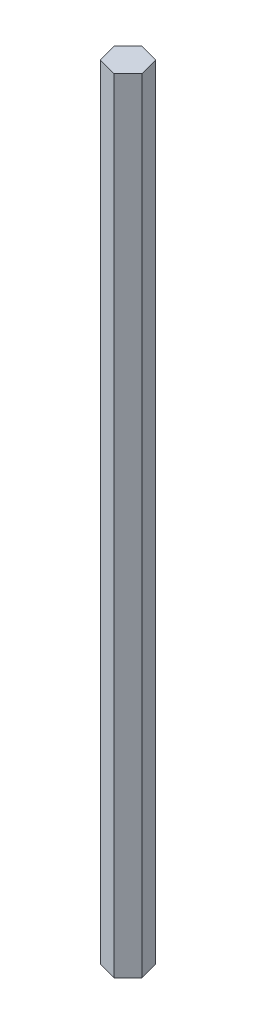
from build123d import *

# Parameters (mm, degrees)
BOSS_EXTRUDE1_DEPTH = 279.4


with BuildPart() as part:
    # Sketch1 → Boss-Extrude1 (new body)
    with BuildSketch(Plane(origin=(0, 0, 0), x_dir=(1, 0, 0), z_dir=(0, 1, 0))):
        Polygon((4.93859044, 4.93859044), (-1.80764956, 6.74624), (-6.74624, 1.80764956), (-4.93859044, -4.93859044), (1.80764956, -6.74624), (6.74624, -1.80764956), align=None)
    extrude(amount=BOSS_EXTRUDE1_DEPTH)


solid = part.part
